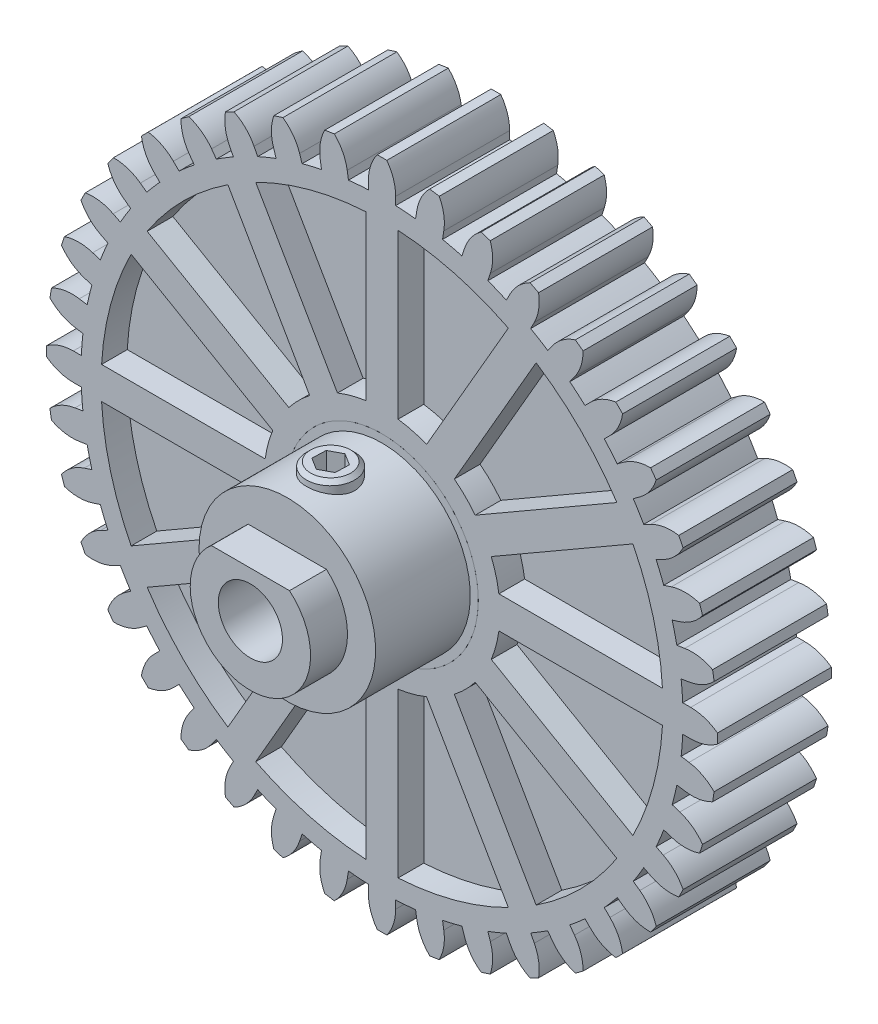
from build123d import *

# Parameters (mm, degrees)
SKETCH5_R           = 1.25
CUT_EXTRUDE1_DEPTH  = 7
SKETCH6_W           = 4.874423042
SKETCH6_H           = 1.8
CUT_EXTRUDE2_DEPTH  = 3.3000001
SKETCH1_R           = 18.75
SKETCH1_R_2         = 6
BOSS_EXTRUDE1_DEPTH = 7.1
BOSS_EXTRUDE2_DEPTH = 7.1
CIRPATTERN1_COUNT   = 40
CUT_EXTRUDE3_DEPTH  = 1.6
CUT_EXTRUDE4_DEPTH  = 1.6
CIRPATTERN2_COUNT   = 12
SKETCH9_R           = 1.5
BOSS_EXTRUDE3_DEPTH = 4.6
CHAMFER1_SIZE       = 0.25
CUT_EXTRUDE5_DEPTH  = 2


with BuildPart() as part:
    # Sketch4 → Revolve1 (revolve)
    with BuildSketch(Plane(origin=(0, 0, 0), x_dir=(1, 0, 0), z_dir=(0, 1, 0))):
        Polygon((2, 0.5), (2, -15.3), (3.75, -15.3), (3.75, -13), (5.5, -13), (5.5, -7.1), (6, -7.1), (6, 0), (5.5, 0), (5.5, 0.5), align=None)
    revolve(axis=Axis((0, 0, -23.226019237), (0, 0, 1)))

    # Sketch5 → Cut-Extrude1 (cut, through all)
    with BuildSketch(Plane(origin=(0, 0, 0), x_dir=(1, 0, 0), z_dir=(0, 1, 0))):
        with Locations((0, -10.3)):
            Circle(SKETCH5_R)
    extrude(amount=CUT_EXTRUDE1_DEPTH, mode=Mode.SUBTRACT)

    # Sketch6 → Cut-Extrude2 (cut, through all)
    with BuildSketch(Plane.XY.offset(13)):
        with Locations((0, 3.75)):
            Rectangle(SKETCH6_W, SKETCH6_H)
    extrude(amount=CUT_EXTRUDE2_DEPTH, mode=Mode.SUBTRACT)


with BuildPart() as body_2:
    # Sketch1 → Boss-Extrude1 (new body)
    with BuildSketch(Plane.XY):
        Circle(SKETCH1_R)
        Circle(SKETCH1_R_2, mode=Mode.SUBTRACT)
    extrude(amount=BOSS_EXTRUDE1_DEPTH)

    # Sketch2 → Boss-Extrude2 (add)
    with BuildSketch(Plane.XY):
        with BuildLine():
            Line((0.85, 18.730723424), (0.85, 19.230723424))
            ThreePointArc((0.85, 19.230723424), (0.708949346, 20.108476277), (0.3, 20.897846779))
            ThreePointArc((0.3, 20.897846779), (0, 20.9), (-0.3, 20.897846779))
            ThreePointArc((-0.3, 20.897846779), (-0.708949346, 20.108476277), (-0.85, 19.230723424))
            Line((-0.85, 19.230723424), (-0.85, 18.730723424))
            Line((-0.85, 18.730723424), (0.85, 18.730723424))
        make_face()
    boss_extrude2 = extrude(amount=BOSS_EXTRUDE2_DEPTH)

    # CirPattern1: Boss-Extrude2 ×40 about axis
    cirpattern1_axis = Axis((0, 0, 0), (0, 0, 1))
    for i in range(1, CIRPATTERN1_COUNT):
        add(boss_extrude2.rotate(cirpattern1_axis, i * 360 / CIRPATTERN1_COUNT))

    # Sketch7 → Cut-Extrude3 (cut)
    with BuildSketch(Plane.XY.offset(7.1)):
        with BuildLine():
            Line((7.869677201, 15.630680751), (2.774802112, 6.806098239))
            ThreePointArc((2.774802112, 6.806098239), (1.902319982, 7.099554823), (1, 7.281655032))
            Line((1, 7.281655032), (1, 17.47140521))
            ThreePointArc((1, 17.47140521), (4.529333289, 16.90370196), (7.869677201, 15.630680751))
        make_face()
    cut_extrude3 = extrude(amount=-CUT_EXTRUDE3_DEPTH, mode=Mode.SUBTRACT)

    # Sketch8 → Cut-Extrude4 (cut)
    with BuildSketch(Plane(origin=(0, 0, 0), x_dir=(-1, 0, 0), z_dir=(0, 0, -1))):
        with BuildLine():
            Line((-7.869677201, 15.630680751), (-2.774802112, 6.806098239))
            ThreePointArc((-2.774802112, 6.806098239), (-1.902319982, 7.099554823), (-1, 7.281655032))
            Line((-1, 7.281655032), (-1, 17.47140521))
            ThreePointArc((-1, 17.47140521), (-4.529333289, 16.90370196), (-7.869677201, 15.630680751))
        make_face()
    cut_extrude4 = extrude(amount=-CUT_EXTRUDE4_DEPTH, mode=Mode.SUBTRACT)

    # CirPattern2: Cut-Extrude3, Cut-Extrude4 ×12 about axis
    cirpattern2_axis = Axis((0, 0, 0), (0, 0, 1))
    for i in range(1, CIRPATTERN2_COUNT):
        add(cut_extrude3.rotate(cirpattern2_axis, i * 360 / CIRPATTERN2_COUNT), mode=Mode.SUBTRACT)
        add(cut_extrude4.rotate(cirpattern2_axis, i * 360 / CIRPATTERN2_COUNT), mode=Mode.SUBTRACT)


with BuildPart() as body_3:
    # Sketch9 → Boss-Extrude3 (new body)
    with BuildSketch(Plane(origin=(0, 1.5, 0), x_dir=(1, 0, 0), z_dir=(0, 1, 0))):
        with Locations((0, -10.3)):
            Circle(SKETCH9_R)
    extrude(amount=BOSS_EXTRUDE3_DEPTH)

    # Chamfer1
    chamfer1_edges = [body_3.edges().sort_by_distance(p)[0] for p in [
        (-1.5, 6.1, 10.3),
    ]]
    chamfer(chamfer1_edges, length=CHAMFER1_SIZE)

    # Sketch10 → Cut-Extrude5 (cut)
    with BuildSketch(Plane(origin=(0, 6.1, 0), x_dir=(1, 0, 0), z_dir=(0, 1, 0))):
        Polygon((0.733584434, -10.760275871), (0.765402814, -9.89483518), (0.03181838, -9.434559308), (-0.733584434, -9.839724129), (-0.765402814, -10.70516482), (-0.03181838, -11.165440692), align=None)
    extrude(amount=-CUT_EXTRUDE5_DEPTH, mode=Mode.SUBTRACT)


solid = Compound([part.part, body_2.part, body_3.part])
